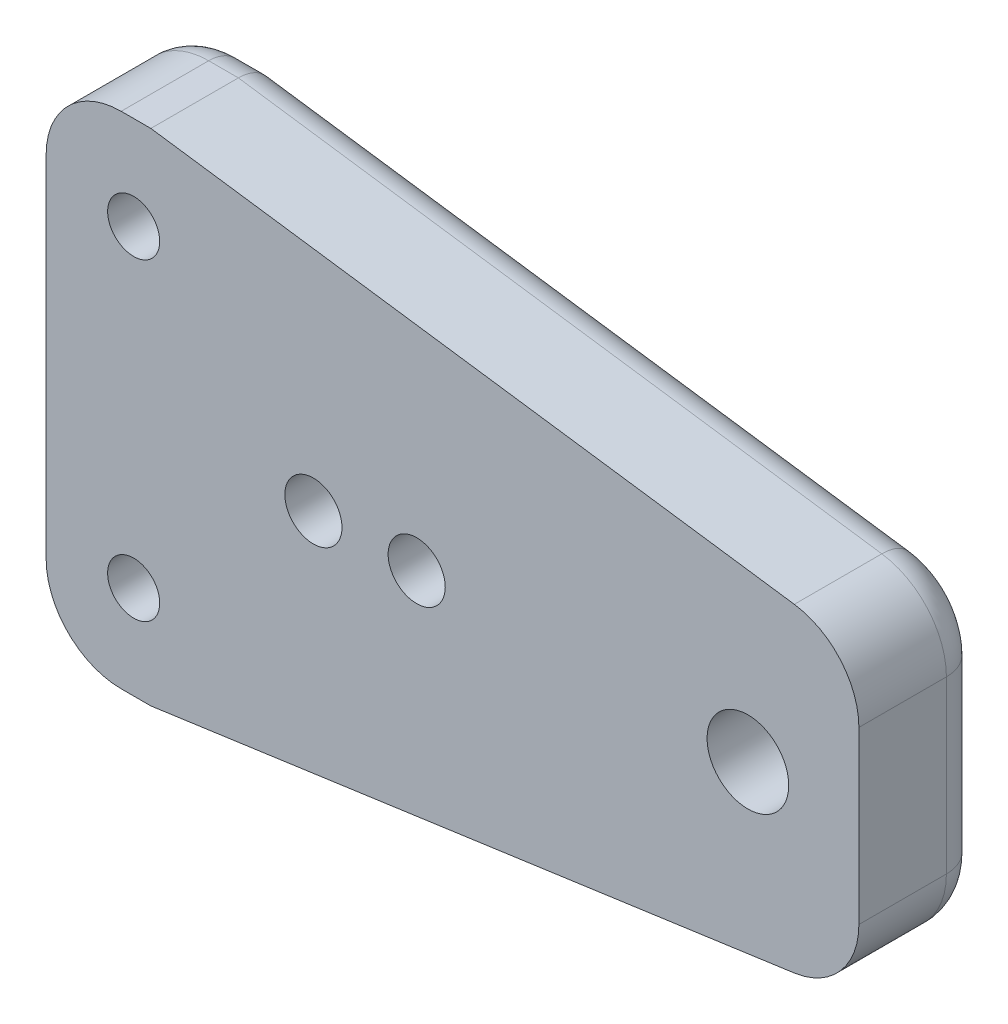
from build123d import *

# Parameters (mm, degrees)
SKETCH1_R            = 2.0828
SKETCH1_R_2          = 3.2639
BASE_EXTRUDE_DEPTH   = 10
SKETCH3_R            = 2.285
HOLES_TO_CLAMP_DEPTH = 11
FILLET2_R            = 3


with BuildPart() as part:
    # Sketch1 → Base-Extrude (new body)
    with BuildSketch(Plane.XY):
        with BuildLine():
            Line((-90.124126187, 20), (-87.749643874, 20))
            Line((-87.749643874, 20), (-36.289087581, 12.767690464))
            ThreePointArc((-36.289087581, 12.767690464), (-32.595868705, 10.762436226), (-31.124126187, 6.826082052))
            Line((-31.124126187, 6.826082052), (-31.124126187, -6.826082052))
            ThreePointArc((-31.124126187, -6.826082052), (-32.595868705, -10.762436226), (-36.289087581, -12.767690464))
            Line((-36.289087581, -12.767690464), (-87.749643874, -20))
            Line((-87.749643874, -20), (-90.124126187, -20))
            ThreePointArc((-90.124126187, -20), (-94.366766874, -18.242640687), (-96.124126187, -14))
            Line((-96.124126187, -14), (-96.124126187, 14))
            ThreePointArc((-96.124126187, 14), (-94.366766874, 18.242640687), (-90.124126187, 20))
        make_face()
        with Locations((-89.124126187, 12.525579086)):
            Circle(SKETCH1_R, mode=Mode.SUBTRACT)
        with Locations((-40, 0)):
            Circle(SKETCH1_R_2, mode=Mode.SUBTRACT)
        with Locations((-89.124126187, -12.525579086)):
            Circle(SKETCH1_R, mode=Mode.SUBTRACT)
    extrude(amount=BASE_EXTRUDE_DEPTH)

    # Sketch3 → Holes to Clamp (cut, through all)
    with BuildSketch(Plane.XY.offset(10)):
        with Locations((-66.489576187, 0)):
            Circle(SKETCH3_R)
        with Locations((-74.749576187, 0)):
            Circle(SKETCH3_R)
    extrude(amount=-HOLES_TO_CLAMP_DEPTH, mode=Mode.SUBTRACT)

    # Fillet2
    fillet2_edges = [part.edges().sort_by_distance(p)[0] for p in [
        (-88.93688503, 20, 0),
        (-62.019365727, 16.383845232, 0),
        (-32.595868705, 10.762436226, 0),
        (-31.124126187, 0, 0),
        (-32.595868705, -10.762436226, 0),
        (-62.019365727, -16.383845232, 0),
        (-88.93688503, -20, 0),
        (-94.366766874, -18.242640687, 0),
        (-96.124126187, 0, 0),
        (-94.366766874, 18.242640687, 0),
    ]]
    fillet(fillet2_edges, radius=FILLET2_R)


solid = part.part
